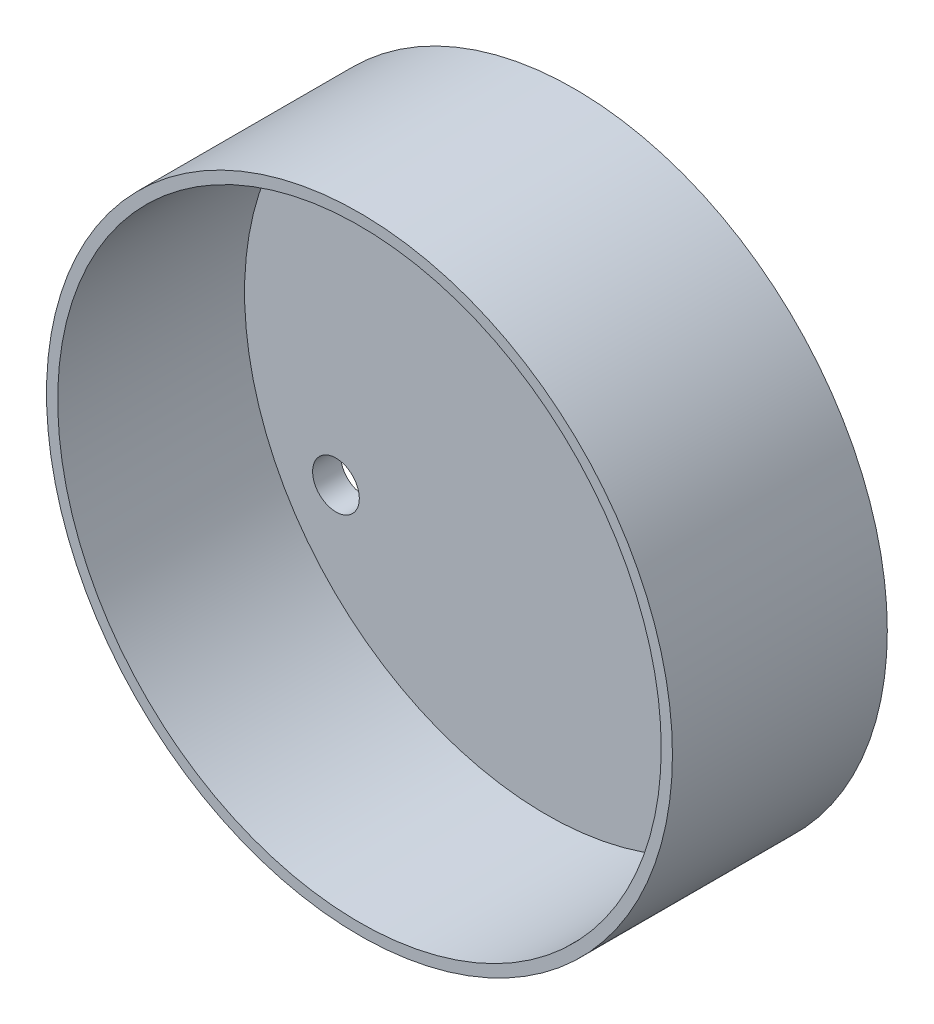
from build123d import *

# Parameters (mm, degrees)
SKETCH_1_R      = 16.75
SKETCH_1_R_2    = 1.25
EXTRUDE_1_DEPTH = 1.5
SKETCH_2_R      = 16.75
SKETCH_2_R_2    = 16.15
EXTRUDE_2_DEPTH = 10


with BuildPart() as part:
    # 草图1 → 凸台-拉伸1 (new body)
    with BuildSketch(Plane.XY):
        Circle(SKETCH_1_R)
        with Locations((0, 13)):
            Circle(SKETCH_1_R_2, mode=Mode.SUBTRACT)
        with Locations((11.258330249, -6.5)):
            Circle(SKETCH_1_R_2, mode=Mode.SUBTRACT)
        with Locations((-11.258330249, -6.5)):
            Circle(SKETCH_1_R_2, mode=Mode.SUBTRACT)
    extrude(amount=EXTRUDE_1_DEPTH)

    # 草图2 → 凸台-拉伸2 (add)
    with BuildSketch(Plane.XY.offset(1.5)):
        Circle(SKETCH_2_R)
        Circle(SKETCH_2_R_2, mode=Mode.SUBTRACT)
    extrude(amount=EXTRUDE_2_DEPTH)


solid = part.part
